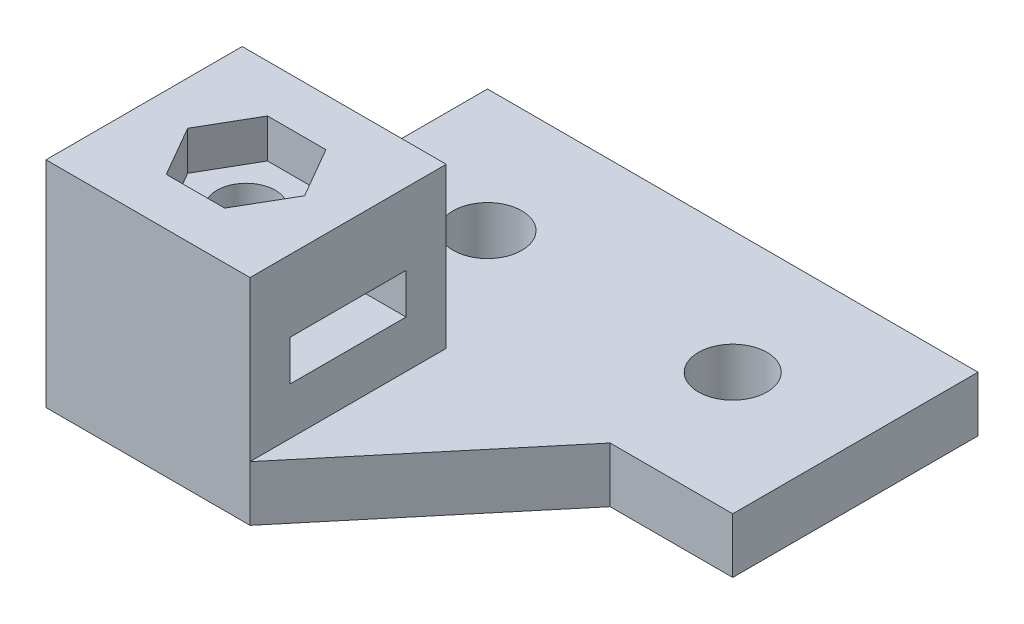
from build123d import *

# Parameters (mm, degrees)
SKETCH1_R           = 2.8
BOSS_EXTRUDE1_DEPTH = 4.5
SKETCH1_3_W         = 16.636354437
SKETCH1_3_H         = 16
BOSS_EXTRUDE2_DEPTH = 17.5
SKETCH2_W           = 9.45
SKETCH2_H           = 3.3
CUT_EXTRUDE1_DEPTH  = 40.091046724
CUT_EXTRUDE2_DEPTH  = 3.18
CUT_EXTRUDE3_REACH  = 45.385
SKETCH5_3_R         = 2.38125


with BuildPart() as part:
    # Sketch1 → Boss-Extrude1 (new body)
    with BuildSketch(Plane(origin=(0, 0, 0), x_dir=(1, 0, 0), z_dir=(0, 1, 0))):
        Polygon((30, 10), (-10, 10), (-10, -10), (6.636354437, -10), (6.636354437, -26), (20, -10), (30, -10), align=None)
        Circle(SKETCH1_R, mode=Mode.SUBTRACT)
        with Locations((20, 0)):
            Circle(SKETCH1_R, mode=Mode.SUBTRACT)
    extrude(amount=BOSS_EXTRUDE1_DEPTH)

    # Sketch1_3 → Boss-Extrude2 (add)
    with BuildSketch(Plane(origin=(0, 0, 0), x_dir=(1, 0, 0), z_dir=(0, 1, 0))):
        with Locations((-1.681822781, -18)):
            Rectangle(SKETCH1_3_W, SKETCH1_3_H)
    extrude(amount=BOSS_EXTRUDE2_DEPTH)

    # Sketch2 → Cut-Extrude1 (cut, through all)
    with BuildSketch(Plane(origin=(6.636354437, 0, 0), x_dir=(0, 0, -1), z_dir=(1, 0, 0))):
        with Locations((-18, 10)):
            Rectangle(SKETCH2_W, SKETCH2_H)
    extrude(amount=-CUT_EXTRUDE1_DEPTH, mode=Mode.SUBTRACT)

    # Sketch5 → Cut-Extrude2 (cut)
    with BuildSketch(Plane(origin=(0, 17.5, 0), x_dir=(1, 0, 0), z_dir=(0, 1, 0))):
        Polygon((0.701190454, -13.8725), (-4.064836018, -13.8725), (-6.447849254, -18), (-4.064836018, -22.1275), (0.701190454, -22.1275), (3.08420369, -18), align=None)
    extrude(amount=-CUT_EXTRUDE2_DEPTH, mode=Mode.SUBTRACT)

    # Sketch5_3 → Cut-Extrude3 (cut, up to next)
    with BuildSketch(Plane(origin=(0, 17.5, 0), x_dir=(1, 0, 0), z_dir=(0, 1, 0)), mode=Mode.PRIVATE) as cut_extrude3_sk1:
        with Locations((-1.681822782, -18)):
            Circle(SKETCH5_3_R)
    cut_extrude3_tool1 = extrude(cut_extrude3_sk1.sketch, amount=-CUT_EXTRUDE3_REACH, mode=Mode.PRIVATE) & part.part
    add(cut_extrude3_tool1.solids().sort_by_distance((-1.681823, 17.5, 18))[0], mode=Mode.SUBTRACT)


solid = part.part
